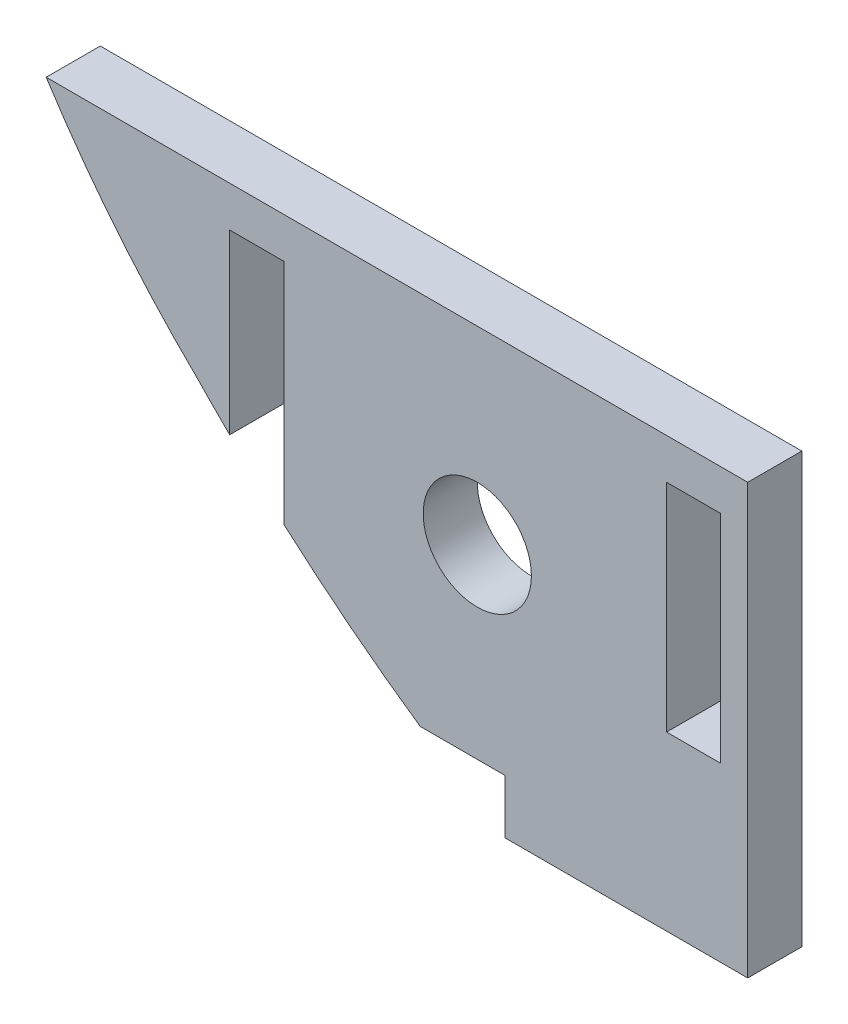
from build123d import *

# Parameters (mm, degrees)
SKETCH1_R           = 2
SKETCH1_W           = 2
SKETCH1_H           = 8
BOSS_EXTRUDE1_DEPTH = 2


with BuildPart() as part:
    # Sketch1 → Boss-Extrude1 (new body)
    with BuildSketch(Plane.XY):
        with BuildLine():
            Line((-6.654132998, -12.706050279), (-6.654132998, -10.706050279))
            Line((-6.654132998, -10.706050279), (-9.783639909, -10.706050279))
            ThreePointArc((-9.783639909, -10.706050279), (-12.367491039, -8.806551261), (-14.831802528, -6.754344625))
            Line((-14.831802528, -6.754344625), (-14.831802528, 1.669576319))
            Line((-14.831802528, 1.669576319), (-16.831802528, 1.669576319))
            Line((-16.831802528, 1.669576319), (-16.831802528, -4.889537014))
            ThreePointArc((-16.831802528, -4.889537014), (-17.420540419, -4.302376557), (-18, -3.706057599))
            ThreePointArc((-18, -3.706057599), (-21.006837803, -0.430380182), (-23.616713146, 3.169576319))
            Line((-23.616713146, 3.169576319), (2.324507934, 3.169576319))
            Line((2.324507934, 3.169576319), (2.324507934, -12.706050279))
            Line((2.324507934, -12.706050279), (-6.654132998, -12.706050279))
        make_face()
        with Locations((-7.675492066, -3.830423681)):
            Circle(SKETCH1_R, mode=Mode.SUBTRACT)
        with Locations((0.324507934, -2.330423681)):
            Rectangle(SKETCH1_W, SKETCH1_H, mode=Mode.SUBTRACT)
    extrude(amount=BOSS_EXTRUDE1_DEPTH)


solid = part.part
